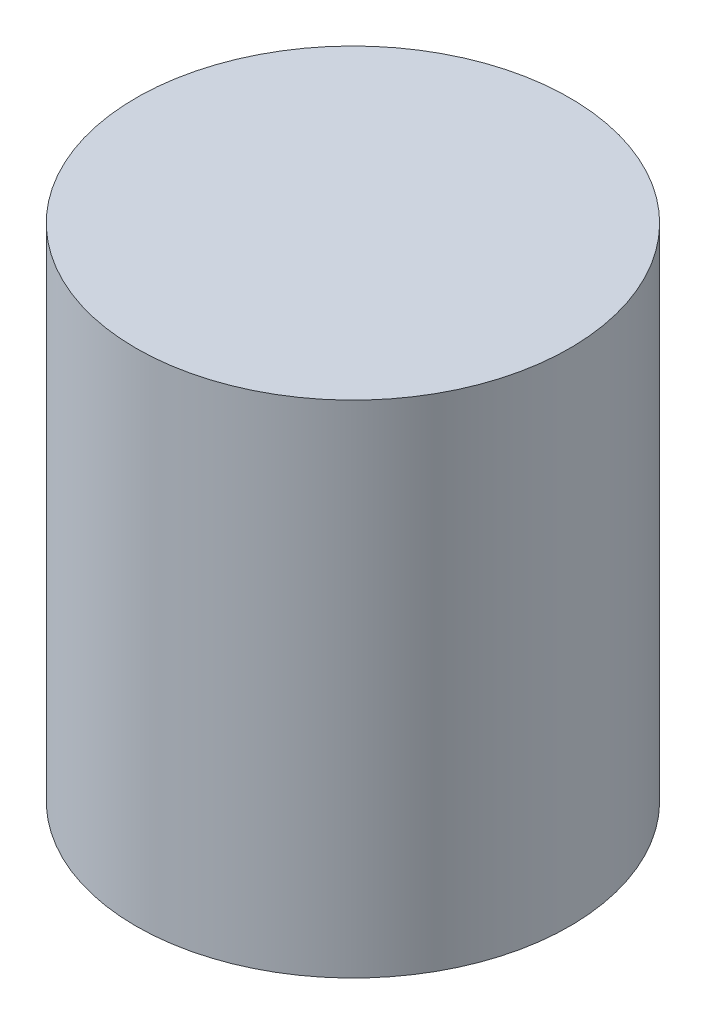
from build123d import *

# Parameters (mm, degrees)
SKETCH1_R           = 130
BOSS_EXTRUDE1_DEPTH = 300
SKETCH2_R           = 125
CUT_EXTRUDE1_DEPTH  = 280


with BuildPart() as part:
    # Sketch1 → Boss-Extrude1 (new body)
    with BuildSketch(Plane(origin=(0, 0, 0), x_dir=(1, 0, 0), z_dir=(0, 1, 0))):
        Circle(SKETCH1_R)
    extrude(amount=-BOSS_EXTRUDE1_DEPTH)

    # Sketch2 → Cut-Extrude1 (cut)
    with BuildSketch(Plane(origin=(0, -300, 0), x_dir=(-1, 0, 0), z_dir=(0, -1, 0))):
        Circle(SKETCH2_R)
    extrude(amount=-CUT_EXTRUDE1_DEPTH, mode=Mode.SUBTRACT)


solid = part.part
